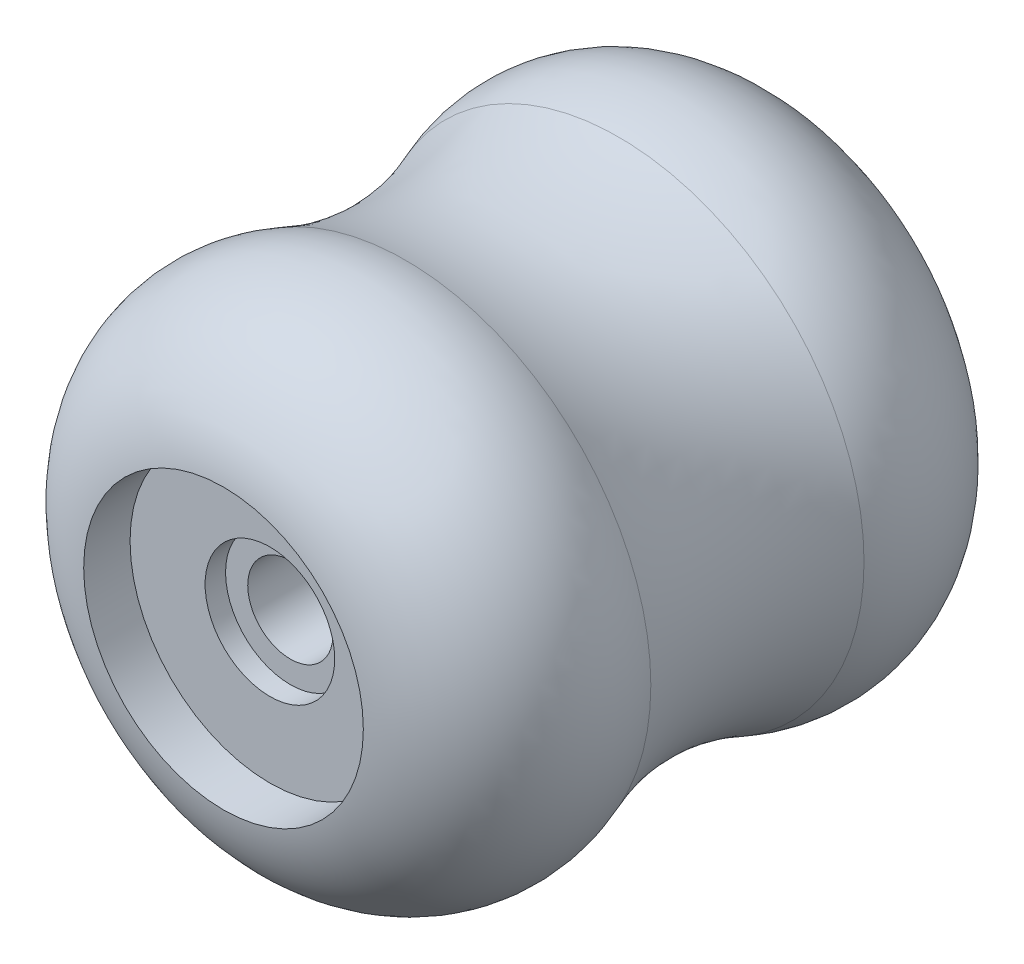
from build123d import *

# Parameters (mm, degrees)
SKETCH2_R          = 10.414
SKETCH2_R_2        = 4.826
CUT_EXTRUDE1_DEPTH = 3.556
SKETCH2_3_R        = 4.826
SKETCH2_3_R_2      = 3.175
CUT_EXTRUDE2_DEPTH = 5.08
SKETCH2_4_R        = 3.175
CUT_EXTRUDE3_DEPTH = 51.839793437


with BuildPart() as part:
    # Sketch1 → Revolve1 (revolve)
    with BuildSketch(Plane(origin=(0, 0, 0), x_dir=(1, 0, 0), z_dir=(0, 1, 0))):
        with BuildLine():
            Line((-8.99509488, -21.59), (0, -21.59))
            Line((0, -21.59), (0, 21.59))
            Line((0, 21.59), (-8.99509488, 21.59))
            ThreePointArc((-8.99509488, 21.59), (-17.248826294, 17.221029702), (-18.27665112, 7.939027771))
            ThreePointArc((-18.27665112, 7.939027771), (-17.145533974, 4.040924256), (-16.764, 0))
            ThreePointArc((-16.764, 0), (-17.145533974, -4.040924256), (-18.27665112, -7.939027771))
            ThreePointArc((-18.27665112, -7.939027771), (-18.957860852, -12.209538391), (-17.768742698, -16.367338972))
            ThreePointArc((-17.768742698, -16.367338972), (-14.100314862, -20.185516743), (-8.99509488, -21.59))
        make_face()
    revolve(axis=Axis((0, 0, 21.59), (0, 0, -1)))

    # Sketch2 → Cut-Extrude1 (cut)
    with BuildSketch(Plane(origin=(0, 0, -21.59), x_dir=(-1, 0, 0), z_dir=(0, 0, -1))):
        Circle(SKETCH2_R)
        Circle(SKETCH2_R_2, mode=Mode.SUBTRACT)
    cut_extrude1 = extrude(amount=-CUT_EXTRUDE1_DEPTH, mode=Mode.SUBTRACT)

    # Sketch2_3 → Cut-Extrude2 (cut)
    with BuildSketch(Plane(origin=(0, 0, -21.59), x_dir=(-1, 0, 0), z_dir=(0, 0, -1))):
        Circle(SKETCH2_3_R)
        Circle(SKETCH2_3_R_2, mode=Mode.SUBTRACT)
    cut_extrude2 = extrude(amount=-CUT_EXTRUDE2_DEPTH, mode=Mode.SUBTRACT)

    # Sketch2_4 → Cut-Extrude3 (cut, through all)
    with BuildSketch(Plane(origin=(0, 0, -21.59), x_dir=(-1, 0, 0), z_dir=(0, 0, -1))):
        Circle(SKETCH2_4_R)
    extrude(amount=-CUT_EXTRUDE3_DEPTH, mode=Mode.SUBTRACT)

    # Mirror1: Cut-Extrude1, Cut-Extrude2 across plane
    add(cut_extrude1.mirror(Plane.XY), mode=Mode.SUBTRACT)
    add(cut_extrude2.mirror(Plane.XY), mode=Mode.SUBTRACT)


solid = part.part
